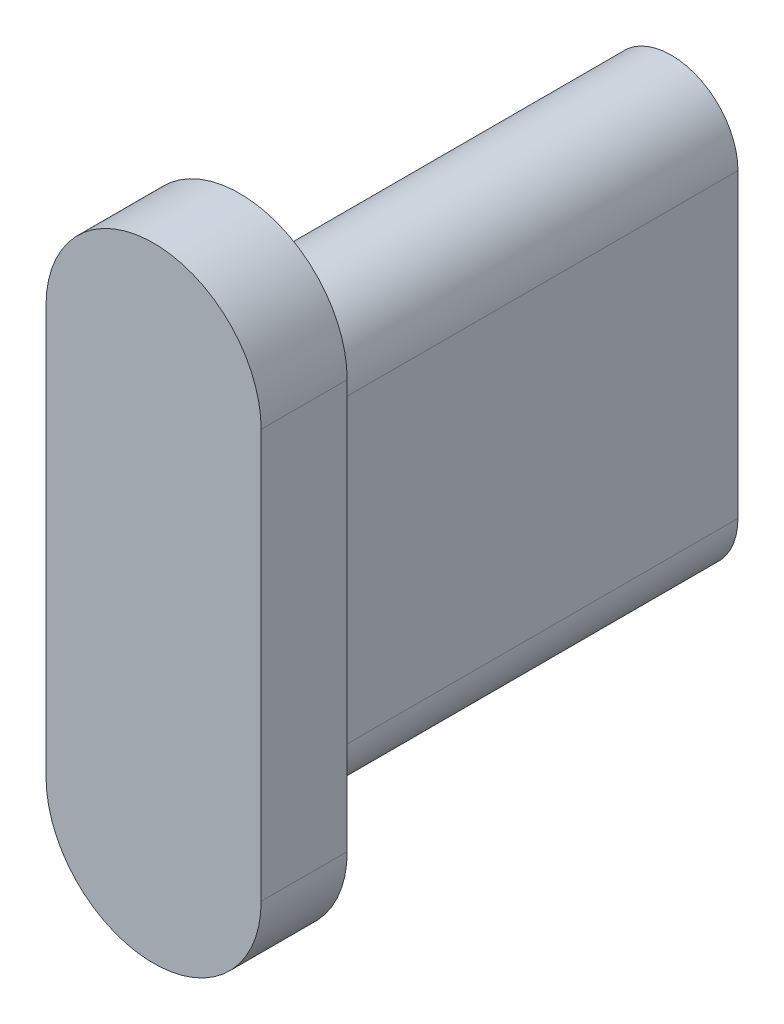
from build123d import *

# Parameters (mm, degrees)
BOSS_EXTRU_3_DEPTH = 10
BOSS_EXTRU_4_DEPTH = 2


with BuildPart() as part:
    # Esquisse1 → Boss.-Extru.3 (new body)
    with BuildSketch(Plane.XY):
        with BuildLine():
            Line((-1.517140129, 11.017733261), (-1.517140129, 4.017733261))
            ThreePointArc((-1.517140129, 4.017733261), (0.032859871, 2.467733261), (1.582859871, 4.017733261))
            Line((1.582859871, 4.017733261), (1.582859871, 11.017733261))
            ThreePointArc((1.582859871, 11.017733261), (0.032859871, 12.567733261), (-1.517140129, 11.017733261))
        make_face()
        with BuildLine():
            Line((-0.517140129, 11.017733261), (-0.517140129, 4.017733261))
            ThreePointArc((-0.517140129, 4.017733261), (0.032859871, 3.467733261), (0.582859871, 4.017733261))
            Line((0.582859871, 4.017733261), (0.582859871, 11.017733261))
            ThreePointArc((0.582859871, 11.017733261), (0.032859871, 11.567733261), (-0.517140129, 11.017733261))
        make_face(mode=Mode.SUBTRACT)
    extrude(amount=-BOSS_EXTRU_3_DEPTH)

    # Esquisse3 → Boss.-Extru.4 (add)
    with BuildSketch(Plane.XY):
        with BuildLine():
            Line((-2.5, 2.767733261), (-2.5, 12.267733261))
            ThreePointArc((-2.5, 12.267733261), (0, 14.767733261), (2.5, 12.267733261))
            Line((2.5, 12.267733261), (2.5, 2.767733261))
            ThreePointArc((2.5, 2.767733261), (0, 0.267733261), (-2.5, 2.767733261))
        make_face()
    extrude(amount=BOSS_EXTRU_4_DEPTH)


solid = part.part
